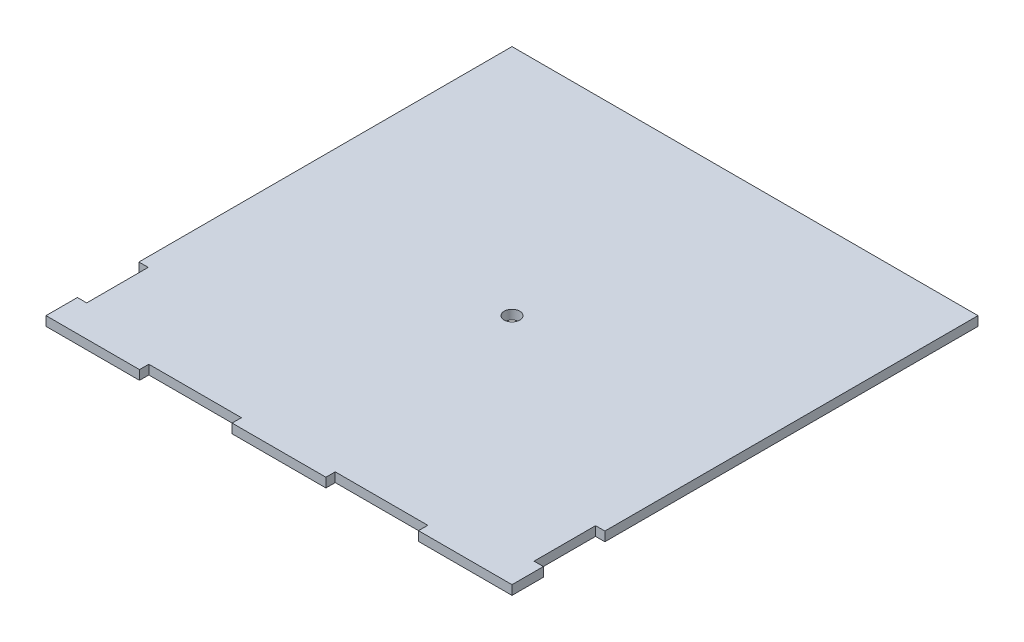
from build123d import *

# Parameters (mm, degrees)
SKETCH1_R           = 2.5
BOSS_EXTRUDE1_DEPTH = 3


with BuildPart() as part:
    # Sketch1 → Boss-Extrude1 (new body)
    with BuildSketch(Plane(origin=(0, 0, 0), x_dir=(1, 0, 0), z_dir=(0, 1, 0))):
        Polygon((59.9, 0), (90.1, 0), (90.1, 3), (119.9, 3), (119.9, 0), (150, 0), (150, 10.1), (147, 10.1), (147, 29.9), (150, 29.9), (150, 150), (0, 150), (0, 29.9), (3, 29.9), (3, 10.1), (0, 10.1), (0, 0), (30.1, 0), (30.1, 3), (59.9, 3), align=None)
        with Locations((75, 75)):
            Circle(SKETCH1_R, mode=Mode.SUBTRACT)
    extrude(amount=BOSS_EXTRUDE1_DEPTH)


solid = part.part
